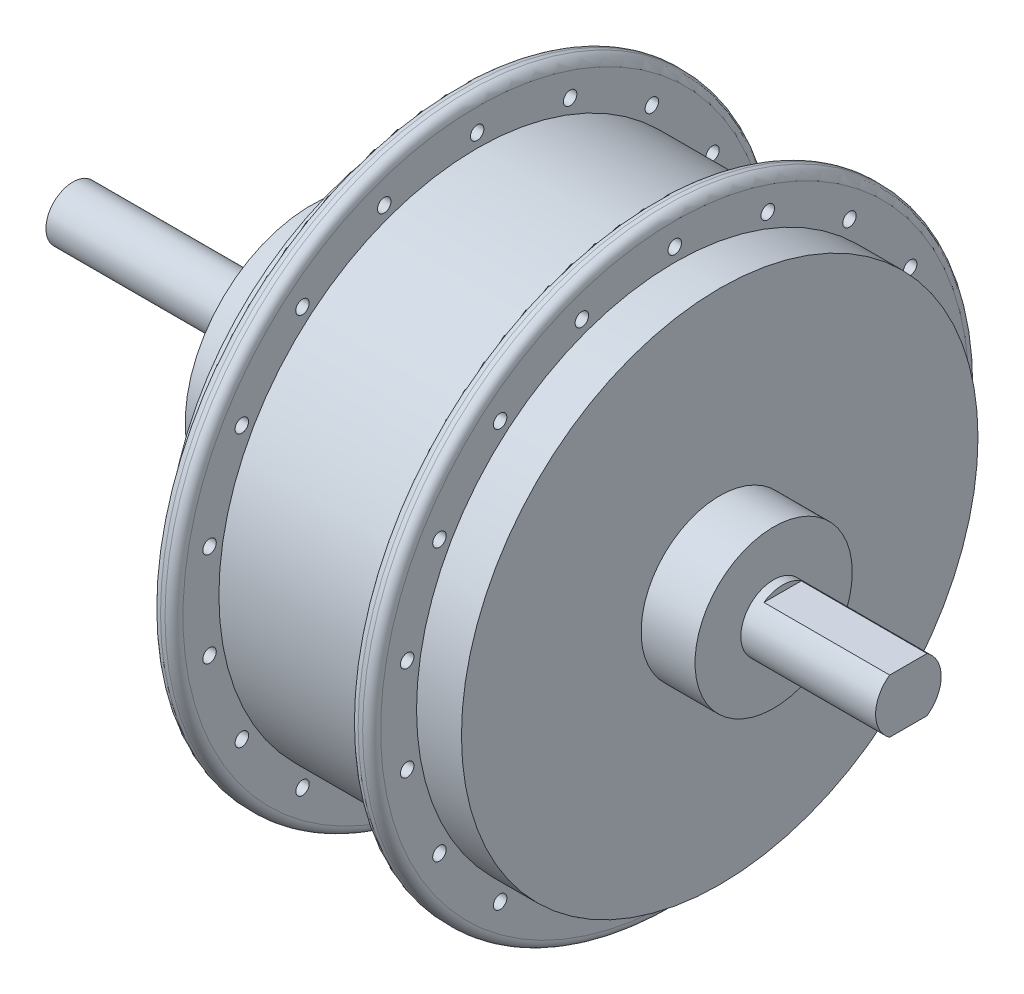
from build123d import *

# Parameters (mm, degrees)
FILLET_1_R           = 2
SKETCH_2_R           = 1.5
CUT_EXTRUDE_1_DEPTH  = 102
SKETCH_3_OUTSIDE_W   = 190.308
SKETCH_3_OUTSIDE_H   = 190.308
SKETCH_3_OUTSIDE_W_2 = 52.638643412
SKETCH_3_OUTSIDE_H_2 = 12
CUT_EXTRUDE_2_DEPTH  = 28


with BuildPart() as part:
    # Эскиз1 → Повернуть1 (revolve)
    with BuildSketch(Plane.XY):
        Polygon((0, 0), (0, 7.3), (-30, 7.3), (-30, 17.5), (-42, 17.5), (-42, 57.5), (-52, 57.5), (-52, 67.5), (-57, 67.5), (-57, 57.5), (-96, 57.5), (-96, 67.5), (-101, 67.5), (-101, 56), (-109, 56), (-109, 50), (-121, 38), (-121, 28), (-133, 28), (-133, 6), (-186, 6), (-186, 0), align=None)
    revolve(axis=Axis((27.635714286, 0, 0), (-1, 0, 0)))

    # Скругление1
    fillet_1_edges = [part.edges().sort_by_distance(p)[0] for p in [
        (-101, -67.5, 0),
        (-96, -67.5, 0),
        (-57, -67.5, 0),
        (-52, -67.5, 0),
    ]]
    fillet(fillet_1_edges, radius=FILLET_1_R)

    # Эскиз2 → Вырез-Вытянуть1 (cut, through all)
    with BuildSketch(Plane.ZY.offset(101)):
        with Locations((0, 60.5)):
            Circle(SKETCH_2_R)
        with Locations((20.692218671, 56.851403558)):
            Circle(SKETCH_2_R)
        with Locations((38.888650386, 46.345688809)):
            Circle(SKETCH_2_R)
        with Locations((52.394536929, 30.25)):
            Circle(SKETCH_2_R)
        with Locations((59.580869057, 10.505714749)):
            Circle(SKETCH_2_R)
        with Locations((59.580869057, -10.505714749)):
            Circle(SKETCH_2_R)
        with Locations((52.394536929, -30.25)):
            Circle(SKETCH_2_R)
        with Locations((38.888650386, -46.345688809)):
            Circle(SKETCH_2_R)
        with Locations((20.692218671, -56.851403558)):
            Circle(SKETCH_2_R)
        with Locations((0, -60.5)):
            Circle(SKETCH_2_R)
        with Locations((-20.692218671, -56.851403558)):
            Circle(SKETCH_2_R)
        with Locations((-38.888650386, -46.345688809)):
            Circle(SKETCH_2_R)
        with Locations((-52.394536929, -30.25)):
            Circle(SKETCH_2_R)
        with Locations((-59.580869057, -10.505714749)):
            Circle(SKETCH_2_R)
        with Locations((-59.580869057, 10.505714749)):
            Circle(SKETCH_2_R)
        with Locations((-52.394536929, 30.25)):
            Circle(SKETCH_2_R)
        with Locations((-38.888650386, 46.345688809)):
            Circle(SKETCH_2_R)
        with Locations((-20.692218671, 56.851403558)):
            Circle(SKETCH_2_R)
    extrude(amount=-CUT_EXTRUDE_1_DEPTH, mode=Mode.SUBTRACT)

    # Эскиз3 outside → Вырез-Вытянуть2 (cut)
    with BuildSketch(Plane(origin=(0, 0, 0), x_dir=(0, 0, -1), z_dir=(1, 0, 0))):
        Rectangle(SKETCH_3_OUTSIDE_W, SKETCH_3_OUTSIDE_H)
        Rectangle(SKETCH_3_OUTSIDE_W_2, SKETCH_3_OUTSIDE_H_2, mode=Mode.SUBTRACT)
    extrude(amount=-CUT_EXTRUDE_2_DEPTH, mode=Mode.SUBTRACT)


solid = part.part
